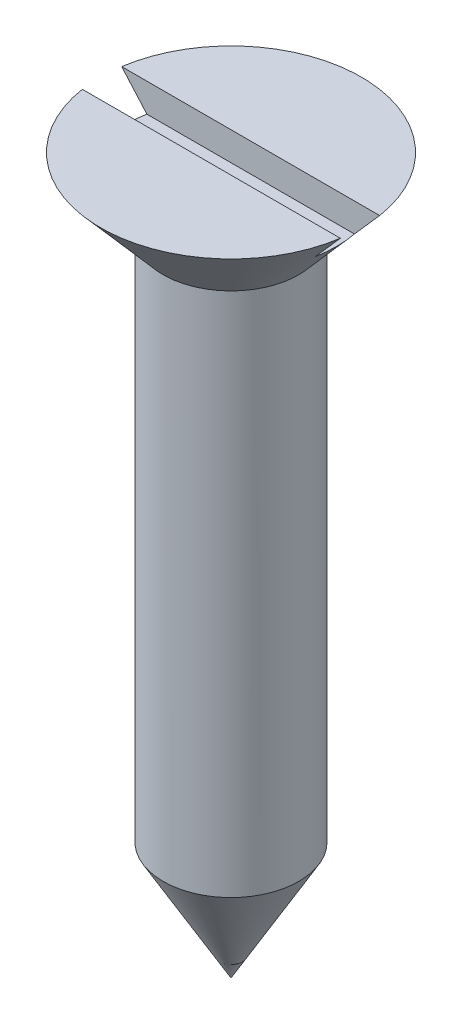
from build123d import *

# Parameters (mm, degrees)
SKETCH1_R           = 2.413
BOSS_EXTRUDE1_DEPTH = 25.4
SKETCH3_W           = 2.413
SKETCH3_H           = 0.635
SKETCH4_W           = 14.174557954
SKETCH4_H           = 1.397
CUT_EXTRUDE1_DEPTH  = 1.016


with BuildPart() as part:
    # Sketch1 → Boss-Extrude1 (new body)
    with BuildSketch(Plane(origin=(0, 0, 0), x_dir=(1, 0, 0), z_dir=(0, 1, 0))):
        Circle(SKETCH1_R)
    extrude(amount=BOSS_EXTRUDE1_DEPTH)

    # Sketch2 → Revolve1 (revolve)
    with BuildSketch(Plane.XY):
        Polygon((0, 25.4), (4.6355, 25.4), (0, 20.067467248), align=None)
    revolve(axis=Axis((0, 20.067467248, 0), (0, 1, 0)))

    # Sketch3 → Cut-Revolve1 (revolve, cut)
    with BuildSketch(Plane.XY):
        Polygon((2.413, 0), (0, 0), (2.413, 4.179438599), align=None)
        with Locations((1.2065, -0.3175)):
            Rectangle(SKETCH3_W, SKETCH3_H)
    revolve(axis=Axis((0, 4.385214031, 0), (0, -1, 0)), mode=Mode.SUBTRACT)

    # Sketch4 → Cut-Extrude1 (cut)
    with BuildSketch(Plane(origin=(0, 25.4, 0), x_dir=(1, 0, 0), z_dir=(0, 1, 0))):
        Rectangle(SKETCH4_W, SKETCH4_H)
    extrude(amount=-CUT_EXTRUDE1_DEPTH, mode=Mode.SUBTRACT)


solid = part.part
